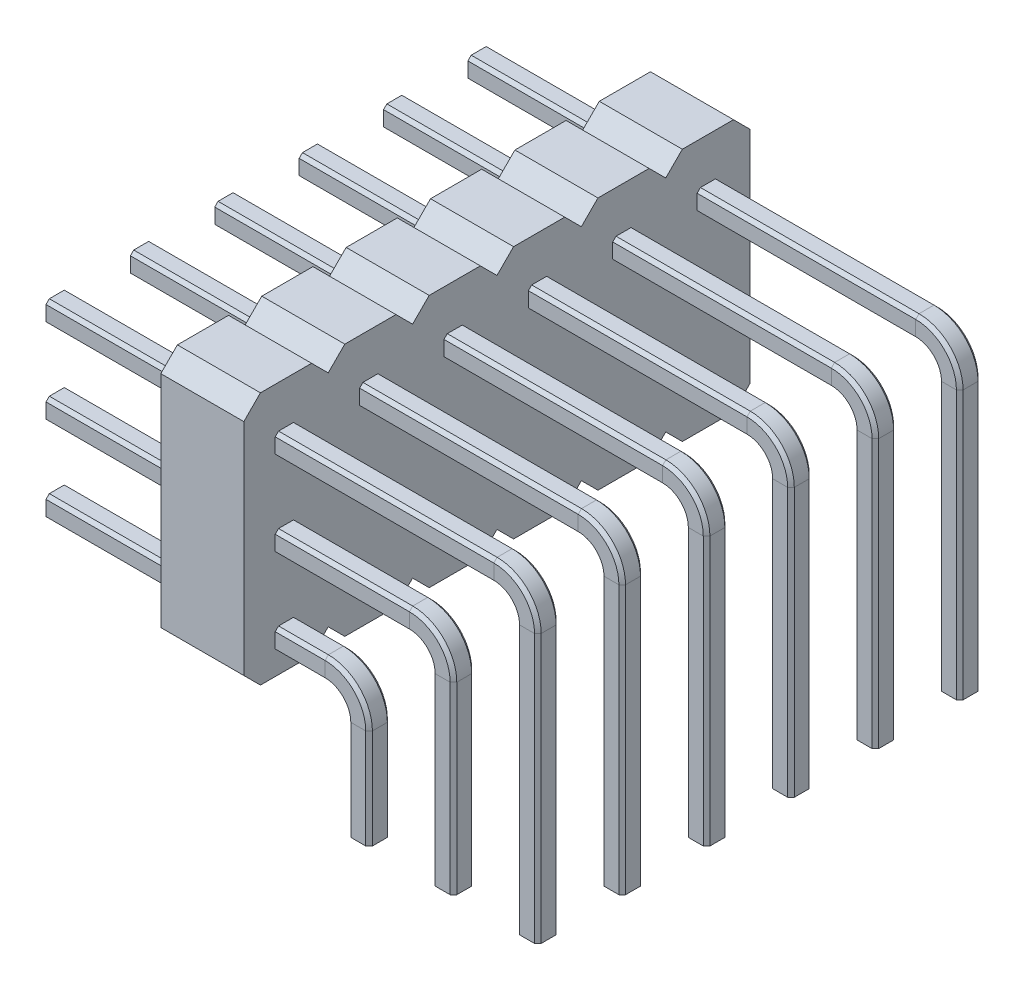
from build123d import *

# Parameters (mm, degrees)
BOSS_EXTRUDE1_DEPTH = 2.5
LPATTERN1_COUNT     = 6
LPATTERN1_PITCH     = 2.54


with BuildPart() as part:
    # Sweep1: sweep along a path in Sketch2
    with BuildLine(Plane.XY) as sweep1_path:
        Line((0, 0), (0, 3))
        ThreePointArc((0, 3), (-0.292893219, 3.707106781), (-1, 4))
        Line((-1, 4), (-9.4, 4))
    # Sketch1 → Sweep1 (sweep)
    with BuildSketch(Plane(origin=(0, 0, 0), x_dir=(1, 0, 0), z_dir=(0, 1, 0))):
        Polygon((-0.325, 0.225), (-0.225, 0.325), (0.225, 0.325), (0.325, 0.225), (0.325, -0.225), (0.225, -0.325), (-0.225, -0.325), (-0.325, -0.225), align=None)
    sweep(path=sweep1_path.line)



with BuildPart() as body_2:
    # Sweep2: sweep along a path in Sketch2_3
    with BuildLine(Plane.XY) as sweep2_path:
        Line((2.54, 0), (2.54, 5.54))
        ThreePointArc((2.54, 5.54), (2.247106781, 6.247106781), (1.54, 6.54))
        Line((1.54, 6.54), (-9.4, 6.54))
    # Sketch1_3 → Sweep2 (sweep)
    with BuildSketch(Plane(origin=(0, 0, 0), x_dir=(1, 0, 0), z_dir=(0, 1, 0))):
        Polygon((2.315, 0.325), (2.765, 0.325), (2.865, 0.225), (2.865, -0.225), (2.765, -0.325), (2.315, -0.325), (2.215, -0.225), (2.215, 0.225), align=None)
    sweep(path=sweep2_path.line)


with BuildPart() as body_3:
    # Sweep3: sweep along a path in Sketch2_4
    with BuildLine(Plane.XY) as sweep3_path:
        Line((5.08, 0), (5.08, 8.08))
        ThreePointArc((5.08, 8.08), (4.787106781, 8.787106781), (4.08, 9.08))
        Line((4.08, 9.08), (-9.4, 9.08))
    # Sketch1_4 → Sweep3 (sweep)
    with BuildSketch(Plane(origin=(0, 0, 0), x_dir=(1, 0, 0), z_dir=(0, 1, 0))):
        Polygon((4.855, 0.325), (5.305, 0.325), (5.405, 0.225), (5.405, -0.225), (5.305, -0.325), (4.855, -0.325), (4.755, -0.225), (4.755, 0.225), align=None)
    sweep(path=sweep3_path.line)


with BuildPart() as part_1:
    add(part.part)

    add(body_2.part)  # Boss-Extrude1 merges body 2

    add(body_3.part)  # Boss-Extrude1 merges body 3
    # Sketch3 → Boss-Extrude1 (add)
    with BuildSketch(Plane(origin=(-2.5, 0, 0), x_dir=(0, 0, -1), z_dir=(1, 0, 0))):
        Polygon((-0.77, 10.675), (0.77, 10.675), (1.27, 10.175), (1.27, 3.555), (0.77, 3.055), (-0.77, 3.055), (-1.27, 3.555), (-1.27, 10.175), align=None)
    extrude(amount=-BOSS_EXTRUDE1_DEPTH)


with BuildPart() as lpattern1_1:
    # LPattern1: pattern copy
    add(part_1.part.moved(Location(Vector(0, 0, 1) * (1 * LPATTERN1_PITCH))))


with BuildPart() as lpattern1_2:
    # LPattern1: pattern copy
    add(part_1.part.moved(Location(Vector(0, 0, 1) * (2 * LPATTERN1_PITCH))))


with BuildPart() as lpattern1_3:
    # LPattern1: pattern copy
    add(part_1.part.moved(Location(Vector(0, 0, 1) * (3 * LPATTERN1_PITCH))))


with BuildPart() as lpattern1_4:
    # LPattern1: pattern copy
    add(part_1.part.moved(Location(Vector(0, 0, 1) * (4 * LPATTERN1_PITCH))))


with BuildPart() as lpattern1_5:
    # LPattern1: pattern copy
    add(part_1.part.moved(Location(Vector(0, 0, 1) * (5 * LPATTERN1_PITCH))))


with BuildPart() as part_2:
    add(part_1.part)

    # Combine1: union LPattern1_1, LPattern1_2, LPattern1_3, LPattern1_4, LPattern1_5
    add(lpattern1_1.part)
    add(lpattern1_2.part)
    add(lpattern1_3.part)
    add(lpattern1_4.part)
    add(lpattern1_5.part)


solid = part_2.part
